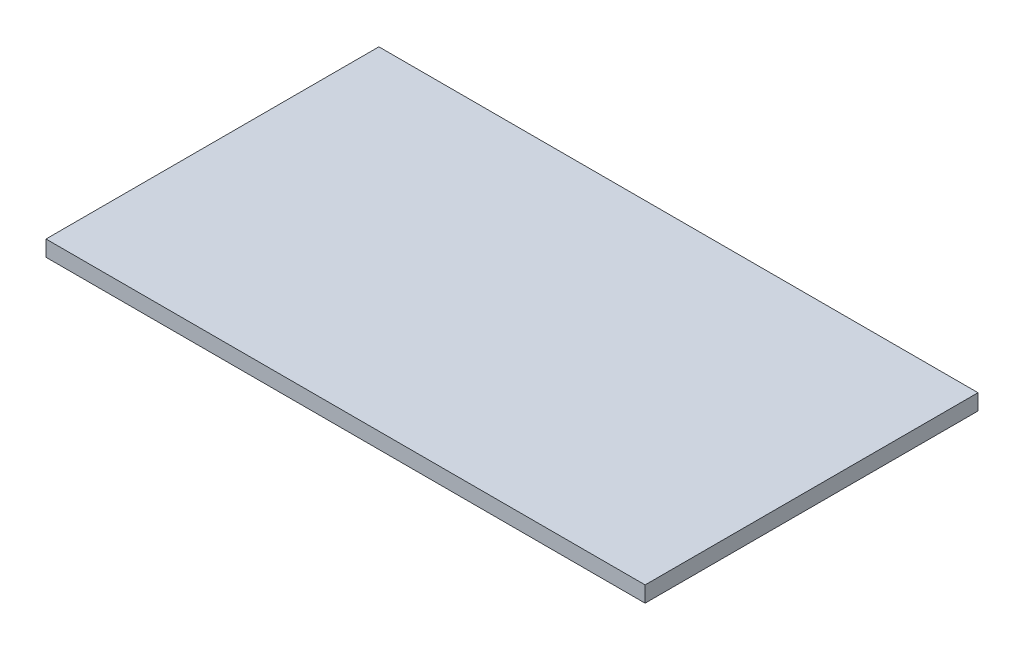
from build123d import *

# Parameters (mm, degrees)
SKETCH1_W           = 120
SKETCH1_H           = 66.675
BOSS_EXTRUDE1_DEPTH = 3.175


with BuildPart() as part:
    # Sketch1 → Boss-Extrude1 (new body)
    with BuildSketch(Plane(origin=(0, 0, 0), x_dir=(1, 0, 0), z_dir=(0, 1, 0))):
        with Locations((31.297270115, -15.172485632)):
            Rectangle(SKETCH1_W, SKETCH1_H)
    extrude(amount=BOSS_EXTRUDE1_DEPTH)


solid = part.part
